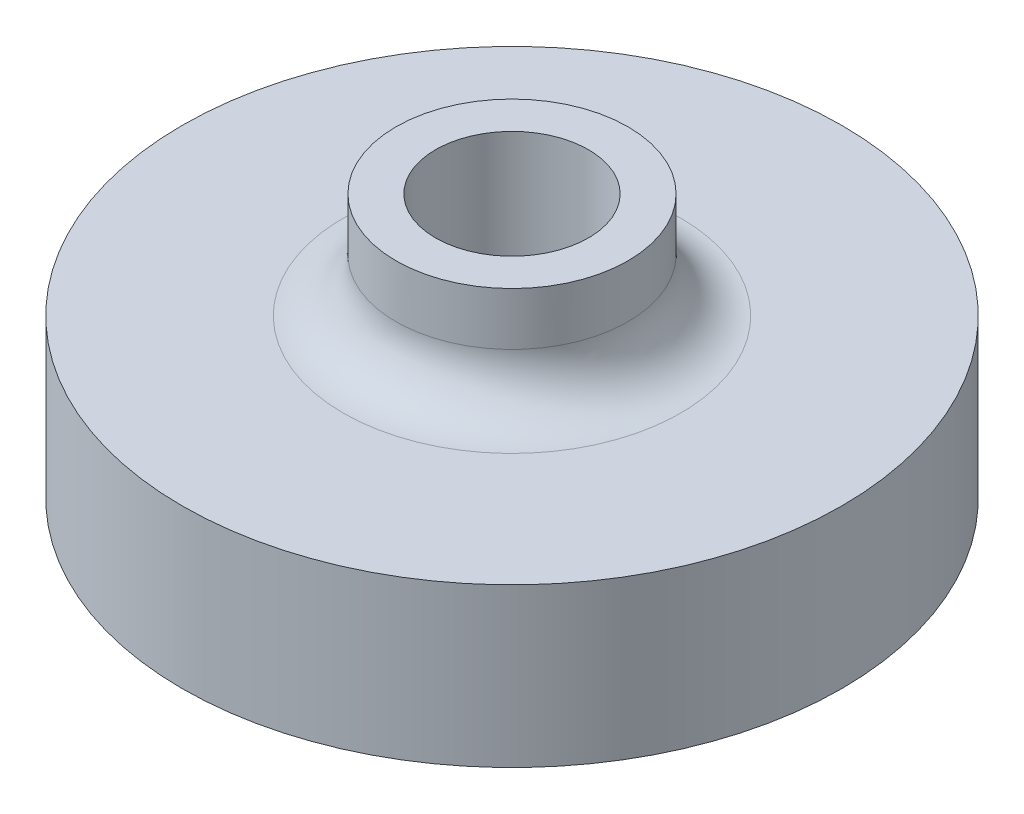
from build123d import *
from build123d.topology import SkipClean

# Parameters (mm, degrees)
SKETCH3_R           = 12.5
BOSS_EXTRUDE1_DEPTH = 10
CUT_EXTRUDE3_DEPTH  = 2.5
SKETCH7_R           = 1.500000283
SKETCH7_R_2         = 1.5
CUT_EXTRUDE4_DEPTH  = 20.403607912
SKETCH8_R           = 2.9
CUT_EXTRUDE5_DEPTH  = 4.5


with BuildPart() as part:
    # Sketch3 → Boss-Extrude1 (new body)
    with BuildSketch(Plane(origin=(0, 0, 0), x_dir=(1, 0, 0), z_dir=(0, 1, 0))):
        with Locations(Location((0, 0, 0), (0, 0, 270))):
            Circle(SKETCH3_R)
    extrude(amount=BOSS_EXTRUDE1_DEPTH)

    # Sketch5 → Cut-Extrude3 (cut)
    with BuildSketch(Plane(origin=(0, 2, 0), x_dir=(-1, 0, 0), z_dir=(0, -1, 0))):
        with BuildLine():
            ThreePointArc((7.910254038, -6.299038106), (9.959292144, -5.75), (9.410254038, -3.700961894))
            Line((9.410254038, -3.700961894), (5.080127019, -1.200961894))
            ThreePointArc((5.080127019, -1.200961894), (3.031088913, -1.75), (3.580127019, -3.799038106))
            Line((3.580127019, -3.799038106), (7.910254038, -6.299038106))
        make_face()
        with BuildLine():
            Line((1.5, 0), (1.5, 4.999998598))
            ThreePointArc((1.5, 4.999998598), (0, 6.499998598), (-1.5, 4.999998598))
            Line((-1.5, 4.999998598), (-1.5, 1.154700538))
            ThreePointArc((-1.5, 1.154700538), (-1.566987298, 0.904700538), (-1.75, 0.721687836))
            Line((-1.75, 0.721687836), (-5.080127019, -1.200961894))
            ThreePointArc((-5.080127019, -1.200961894), (-5.629165611, -3.250000029), (-3.580127396, -3.799038324))
            Line((-3.580127396, -3.799038324), (0.75, -1.299038106))
            ThreePointArc((0.75, -1.299038106), (1.299038106, -0.75), (1.5, 0))
        make_face()
    extrude(amount=-CUT_EXTRUDE3_DEPTH, mode=Mode.SUBTRACT)

    # Sketch7 → Cut-Extrude4 (cut, through all)
    with SkipClean():  # the faces are left unmerged after this step: merging them gives an invalid solid
        with BuildSketch(Plane(origin=(0, 2, 0), x_dir=(-1, 0, 0), z_dir=(0, -1, 0))):
            with Locations(Location((0, 4.999998598, 0), (0, 0, 90))):
                Circle(SKETCH7_R)
            with Locations(Location((-4.330127396, -2.500000218, 0), (0, 0, 90))):
                Circle(SKETCH7_R_2)
            with Locations(Location((0, 0, 0), (0, 0, 90))):
                Circle(SKETCH7_R_2)
            with Locations(Location((8.660254038, -5, 0), (0, 0, 90))):
                Circle(SKETCH7_R_2)
            with Locations(Location((4.330127019, -2.5, 0), (0, 0, 90))):
                Circle(SKETCH7_R_2)
        extrude(amount=CUT_EXTRUDE4_DEPTH, mode=Mode.SUBTRACT)

    # Sketch8 → Cut-Extrude5 (cut)
    with SkipClean():  # the faces are left unmerged after this step: merging them gives an invalid solid
        with BuildSketch(Plane(origin=(0, 10, 0), x_dir=(1, 0, 0), z_dir=(0, 1, 0))):
            with Locations(Location((0, 0, 0), (0, 0, 270))):
                Circle(SKETCH8_R)
        extrude(amount=-CUT_EXTRUDE5_DEPTH, mode=Mode.SUBTRACT)

    # Sketch9 → Cut-Revolve1 (revolve, cut)
    with SkipClean():  # the faces are left unmerged after this step: merging them gives an invalid solid
        with BuildSketch(Plane.XY, mode=Mode.PRIVATE) as cut_revolve1_sk:
            with BuildLine():
                Line((21.498533976, 15.074260083), (4.4, 15.074260083))
                Line((4.4, 15.074260083), (4.4, 8))
                ThreePointArc((4.4, 8), (4.985786438, 6.585786438), (6.4, 6))
                Line((6.4, 6), (21.498533976, 6))
                Line((21.498533976, 6), (21.498533976, 15.074260083))
            make_face()
        revolve(cut_revolve1_sk.sketch.rotate(Axis((0, -2.172857957, 0), (0, 1, 0)), 90), axis=Axis((0, -2.172857957, 0), (0, 1, 0)), mode=Mode.SUBTRACT)


solid = part.part
